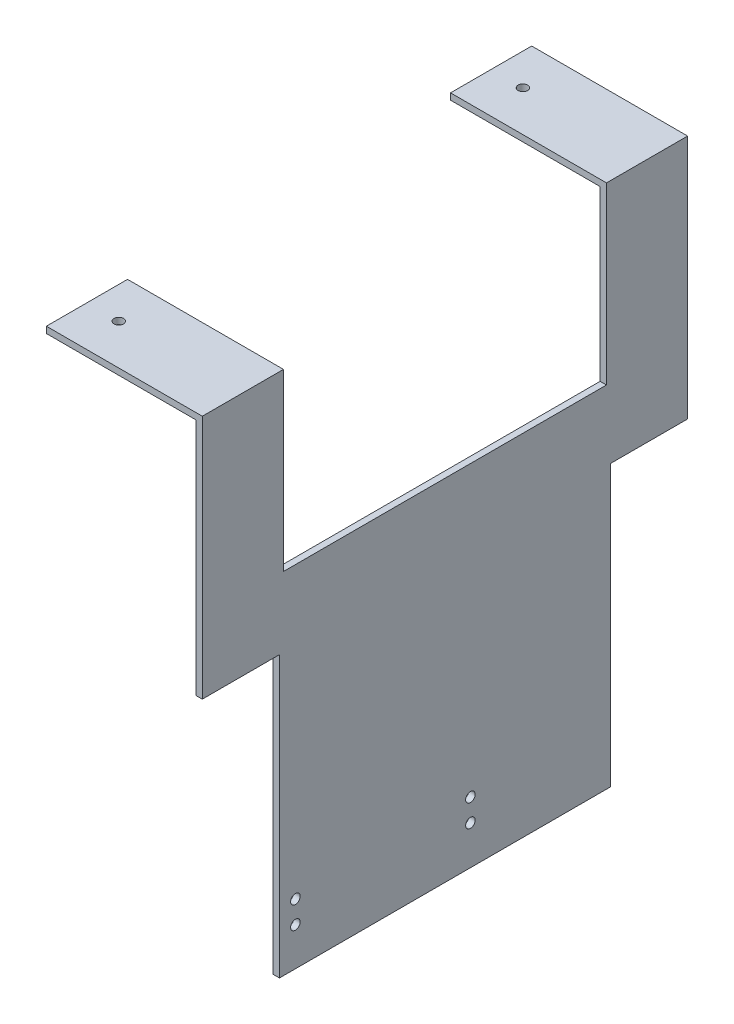
from build123d import *

# Parameters (mm, degrees)
SKETCH2_W             = 49
SKETCH2_H             = 25.5
SKETCH2_R             = 1.5
BOSS_EXTRUDE1_DEPTH   = 2
BOSS_EXTRUDE1_2_DEPTH = 2
SKETCH3_W             = 2
SKETCH3_H             = 25.5
BOSS_EXTRUDE2_DEPTH   = 53
SKETCH4_W             = 152.5
SKETCH4_H             = 22
SKETCH4_W_2           = 104
SKETCH4_H_2           = 88
SKETCH4_R             = 1.5
BOSS_EXTRUDE3_DEPTH   = 2


with BuildPart() as part:
    # Sketch2 → Boss-Extrude1 (new body)
    with BuildSketch(Plane.XZ):
        with Locations((465.5, -63.5)):
            Rectangle(SKETCH2_W, SKETCH2_H)
        with Locations((451, -63.5)):
            Circle(SKETCH2_R, mode=Mode.SUBTRACT)
    extrude(amount=BOSS_EXTRUDE1_DEPTH)



with BuildPart() as body_2:
    # Sketch2 → Boss-Extrude1 2 (new body)
    with BuildSketch(Plane.XZ):
        with Locations((465.5, 63.5)):
            Rectangle(SKETCH2_W, SKETCH2_H)
        with Locations((451, 63.5)):
            Circle(SKETCH2_R, mode=Mode.SUBTRACT)
    extrude(amount=BOSS_EXTRUDE1_2_DEPTH)


with BuildPart() as part_1:
    add(part.part)

    add(body_2.part)  # Boss-Extrude2 merges body 2
    # Sketch3 → Boss-Extrude2 (add)
    with BuildSketch(Plane.XZ.offset(2)):
        with Locations((489, 63.5)):
            Rectangle(SKETCH3_W, SKETCH3_H)
        with Locations((489, -63.5)):
            Rectangle(SKETCH3_W, SKETCH3_H)
    extrude(amount=BOSS_EXTRUDE2_DEPTH)

    # Sketch4 → Boss-Extrude3 (add)
    with BuildSketch(Plane(origin=(490, 0, 0), x_dir=(0, 0, -1), z_dir=(1, 0, 0))):
        with Locations((0, -66)):
            Rectangle(SKETCH4_W, SKETCH4_H)
        with Locations((0, -121)):
            Rectangle(SKETCH4_W_2, SKETCH4_H_2)
        with Locations((-47, -146)):
            Circle(SKETCH4_R, mode=Mode.SUBTRACT)
        with Locations((-47, -153)):
            Circle(SKETCH4_R, mode=Mode.SUBTRACT)
        with Locations((7.999524512, -145.771300426)):
            Circle(SKETCH4_R, mode=Mode.SUBTRACT)
        with Locations((8, -152.77130041)):
            Circle(SKETCH4_R, mode=Mode.SUBTRACT)
    extrude(amount=-BOSS_EXTRUDE3_DEPTH)


solid = part_1.part
